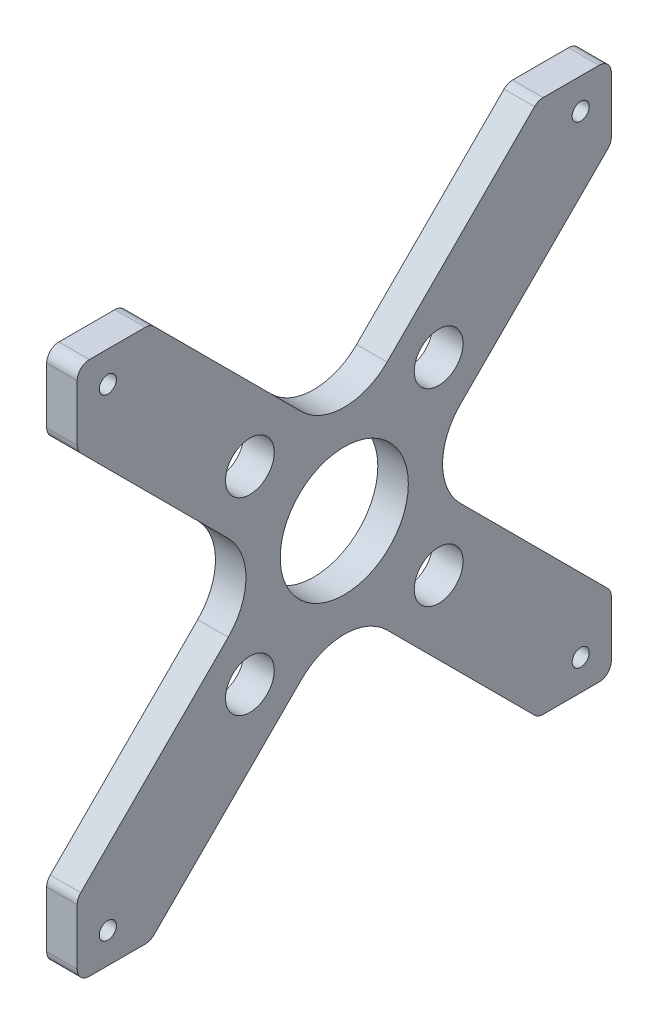
from build123d import *

# Parameters (mm, degrees)
BOSS_EXTRUDE1_DEPTH     = 6.35
SKETCH1_9_R             = 13.335
CUT_EXTRUDE1_DEPTH      = 11.938
SKETCH1_10_R            = 1.778
CUT_EXTRUDE2_DEPTH      = 24.638
SKETCH1_11_R            = 1.778
CUT_EXTRUDE3_DEPTH      = 24.13
SKETCH1_12_R            = 1.778
CUT_EXTRUDE4_DEPTH      = 38.862
SKETCH1_13_R            = 1.778
CUT_EXTRUDE5_DEPTH      = 13.462
FILLET1_R               = 2.54
SKETCH2_R               = 5.08
CUT_EXTRUDE6_DEPTH      = 13.462
MIRROR2_COPY_1_SKETCH_R = 5.08
MIRROR2_COPY_1_DEPTH    = 13.462


with BuildPart() as part:
    # Sketch1 → Boss-Extrude1 (new body)
    with BuildSketch(Plane(origin=(0, 0, 0), x_dir=(0, 0, -1), z_dir=(1, 0, 0))):
        with BuildLine():
            Line((-53.874845122, 46.825199553), (-38.634845122, 46.825199553))
            Line((-38.634845122, 46.825199553), (-7.203948698, 15.394303129))
            ThreePointArc((-7.203948698, 15.394303129), (1.709004986, 11.702436832), (10.621958671, 15.394303129))
            Line((10.621958671, 15.394303129), (42.052855095, 46.825199553))
            Line((42.052855095, 46.825199553), (57.292855095, 46.825199553))
            Line((57.292855095, 46.825199553), (57.292855095, 31.585199553))
            Line((57.292855095, 31.585199553), (25.861958671, 0.154303129))
            ThreePointArc((25.861958671, 0.154303129), (22.170092374, -8.758650555), (25.861958671, -17.67160424))
            Line((25.861958671, -17.67160424), (57.292855095, -49.102500664))
            Line((57.292855095, -49.102500664), (57.292855095, -64.342500664))
            Line((57.292855095, -64.342500664), (42.052855095, -64.342500664))
            Line((42.052855095, -64.342500664), (10.621958671, -32.91160424))
            ThreePointArc((10.621958671, -32.91160424), (1.709004986, -29.219737943), (-7.203948698, -32.91160424))
            Line((-7.203948698, -32.91160424), (-38.634845122, -64.342500664))
            Line((-38.634845122, -64.342500664), (-53.874845122, -64.342500664))
            Line((-53.874845122, -64.342500664), (-53.874845122, -49.102500664))
            Line((-53.874845122, -49.102500664), (-22.443948698, -17.67160424))
            ThreePointArc((-22.443948698, -17.67160424), (-18.752082401, -8.758650555), (-22.443948698, 0.154303129))
            Line((-22.443948698, 0.154303129), (-53.874845122, 31.585199553))
            Line((-53.874845122, 31.585199553), (-53.874845122, 46.825199553))
        make_face()
    extrude(amount=BOSS_EXTRUDE1_DEPTH)

    # Sketch1_9 → Cut-Extrude1 (cut)
    with BuildSketch(Plane(origin=(0, 0, 0), x_dir=(0, 0, -1), z_dir=(1, 0, 0))):
        with Locations((1.709004986, -8.758650555)):
            Circle(SKETCH1_9_R)
    extrude(amount=CUT_EXTRUDE1_DEPTH, mode=Mode.SUBTRACT)

    # Sketch1_10 → Cut-Extrude2 (cut)
    with BuildSketch(Plane(origin=(0, 0, 0), x_dir=(0, 0, -1), z_dir=(1, 0, 0))):
        with Locations((-47.503495014, -57.971150555)):
            Circle(SKETCH1_10_R)
    extrude(amount=CUT_EXTRUDE2_DEPTH, mode=Mode.SUBTRACT)

    # Sketch1_11 → Cut-Extrude3 (cut)
    with BuildSketch(Plane(origin=(0, 0, 0), x_dir=(0, 0, -1), z_dir=(1, 0, 0))):
        with Locations((50.921504986, -57.971150555)):
            Circle(SKETCH1_11_R)
    extrude(amount=CUT_EXTRUDE3_DEPTH, mode=Mode.SUBTRACT)

    # Sketch1_12 → Cut-Extrude4 (cut)
    with BuildSketch(Plane(origin=(0, 0, 0), x_dir=(0, 0, -1), z_dir=(1, 0, 0))):
        with Locations((50.921504986, 40.453849445)):
            Circle(SKETCH1_12_R)
    extrude(amount=CUT_EXTRUDE4_DEPTH, mode=Mode.SUBTRACT)

    # Sketch1_13 → Cut-Extrude5 (cut)
    with BuildSketch(Plane(origin=(0, 0, 0), x_dir=(0, 0, -1), z_dir=(1, 0, 0))):
        with Locations((-47.503495014, 40.453849445)):
            Circle(SKETCH1_13_R)
    extrude(amount=CUT_EXTRUDE5_DEPTH, mode=Mode.SUBTRACT)

    # Fillet1
    fillet1_edges = [part.edges().sort_by_distance(p)[0] for p in [
        (3.175, 31.585199553, -57.292855095),
        (3.175, 46.825199553, -42.052855095),
        (3.175, 46.825199553, -57.292855095),
        (3.175, 31.585199553, 53.874845122),
        (3.175, 46.825199553, 53.874845122),
        (3.175, 46.825199553, 38.634845122),
        (3.175, -64.342500664, 38.634845122),
        (3.175, -49.102500664, 53.874845122),
        (3.175, -64.342500664, 53.874845122),
        (3.175, -64.342500664, -42.052855095),
        (3.175, -64.342500664, -57.292855095),
        (3.175, -49.102500664, -57.292855095),
    ]]
    fillet(fillet1_edges, radius=FILLET1_R)

    # Sketch2 → Cut-Extrude6 (cut)
    with BuildSketch(Plane.ZY):
        with Locations((-21.351416825, 10.883761284)):
            Circle(SKETCH2_R)
    cut_extrude6 = extrude(amount=-CUT_EXTRUDE6_DEPTH, mode=Mode.SUBTRACT)

    # Mirror1: Cut-Extrude6 across plane
    add(cut_extrude6.mirror(Plane.ZX.offset(-8.758650555)), mode=Mode.SUBTRACT)

    # Mirror2: Cut-Extrude6 across plane
    add(cut_extrude6.mirror(Plane.XY.offset(-1.709004986)), mode=Mode.SUBTRACT)

    # Mirror2 copy 1 sketch → Mirror2 copy 1 (cut)
    with BuildSketch(Plane(origin=(0, -17.517301111, -3.418009973), x_dir=(0, 0, -1), z_dir=(-1, 0, 0))):
        with Locations((-21.351416825, 10.883761284)):
            Circle(MIRROR2_COPY_1_SKETCH_R)
    extrude(amount=-MIRROR2_COPY_1_DEPTH, mode=Mode.SUBTRACT)


solid = part.part
